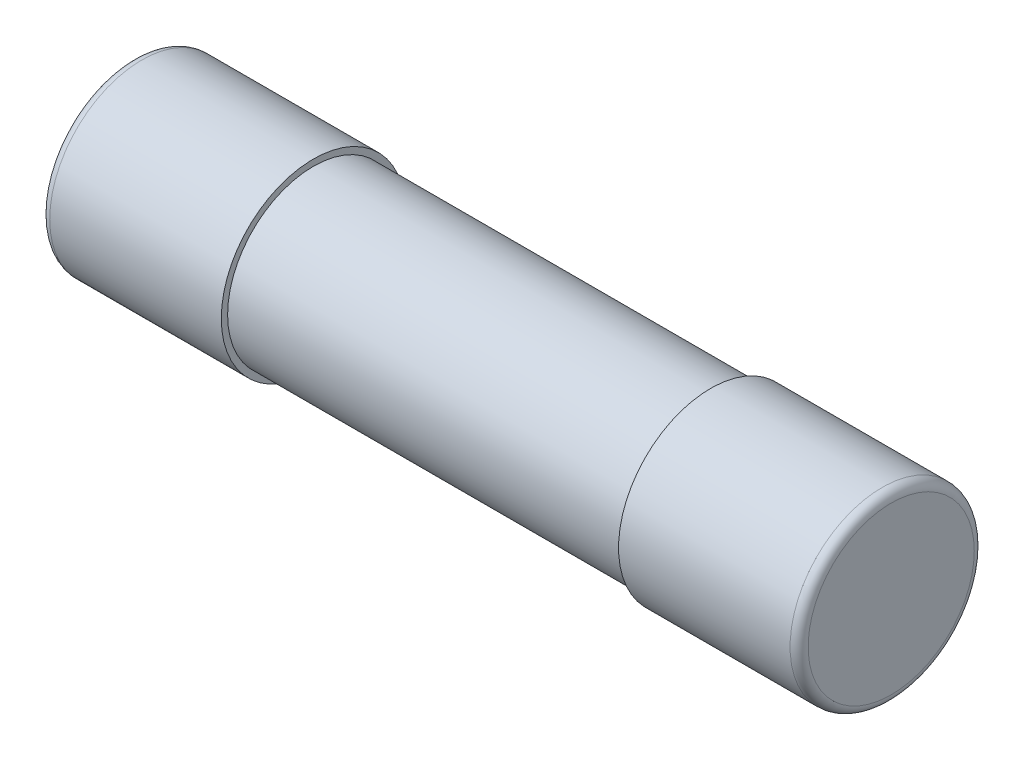
from build123d import *

# Parameters (mm, degrees)
SKETCH1_R           = 2.375
EXTRUDE1_DEPTH      = 10
SHELL1_T            = -0.2
SKETCH2_R           = 0.05
EXTRUDE2_DEPTH      = 9.65
EXTRUDE2_DEPTH_BACK = 9.65
SKETCH7_R           = 2.55
EXTRUDE6_DEPTH      = 5
FILLET2_R           = 0.25
SKETCH8_R           = 2.55
EXTRUDE7_DEPTH      = 5
FILLET3_R           = 0.25


with BuildPart() as part:
    # Sketch1 → Extrude1 (new, symmetric)
    with BuildSketch(Plane(origin=(0, 0, 0), x_dir=(0, 0, -1), z_dir=(1, 0, 0))):
        Circle(SKETCH1_R)
    extrude(amount=EXTRUDE1_DEPTH, both=True)

    # Shell1
    shell1_openings = [part.faces().sort_by_distance(p)[0] for p in [
        (10, 0, 0),
        (-10, 0, 0),
    ]]
    offset(amount=SHELL1_T, openings=shell1_openings, kind=Kind.INTERSECTION)



with BuildPart() as body_2:
    # Sketch2 → Extrude2 (new, two sides)
    with BuildSketch(Plane(origin=(0, 0, 0), x_dir=(0, 0, -1), z_dir=(1, 0, 0))) as extrude2_sk:
        Circle(SKETCH2_R)
    extrude(amount=EXTRUDE2_DEPTH)
    extrude(extrude2_sk.sketch, amount=-EXTRUDE2_DEPTH_BACK)


with BuildPart() as part_1:
    add(part.part)

    add(body_2.part)  # Extrude6 merges body 2
    # Sketch7 → Extrude6 (add)
    with BuildSketch(Plane(origin=(10.5, 0, 0), x_dir=(0, 0, -1), z_dir=(1, 0, 0))):
        Circle(SKETCH7_R)
    extrude(amount=-EXTRUDE6_DEPTH)

    # Fillet2
    fillet2_edges = [part_1.edges().sort_by_distance(p)[0] for p in [
        (10.5, 0, 2.55),
    ]]
    fillet(fillet2_edges, radius=FILLET2_R)

    # Sketch8 → Extrude7 (add)
    with BuildSketch(Plane.ZY.offset(10.5)):
        with Locations(Location((0, 0, 0), (0, 0, 180))):
            Circle(SKETCH8_R)
    extrude(amount=-EXTRUDE7_DEPTH)

    # Fillet3
    fillet3_edges = [part_1.edges().sort_by_distance(p)[0] for p in [
        (-10.5, 0, 2.55),
    ]]
    fillet(fillet3_edges, radius=FILLET3_R)


solid = part_1.part
